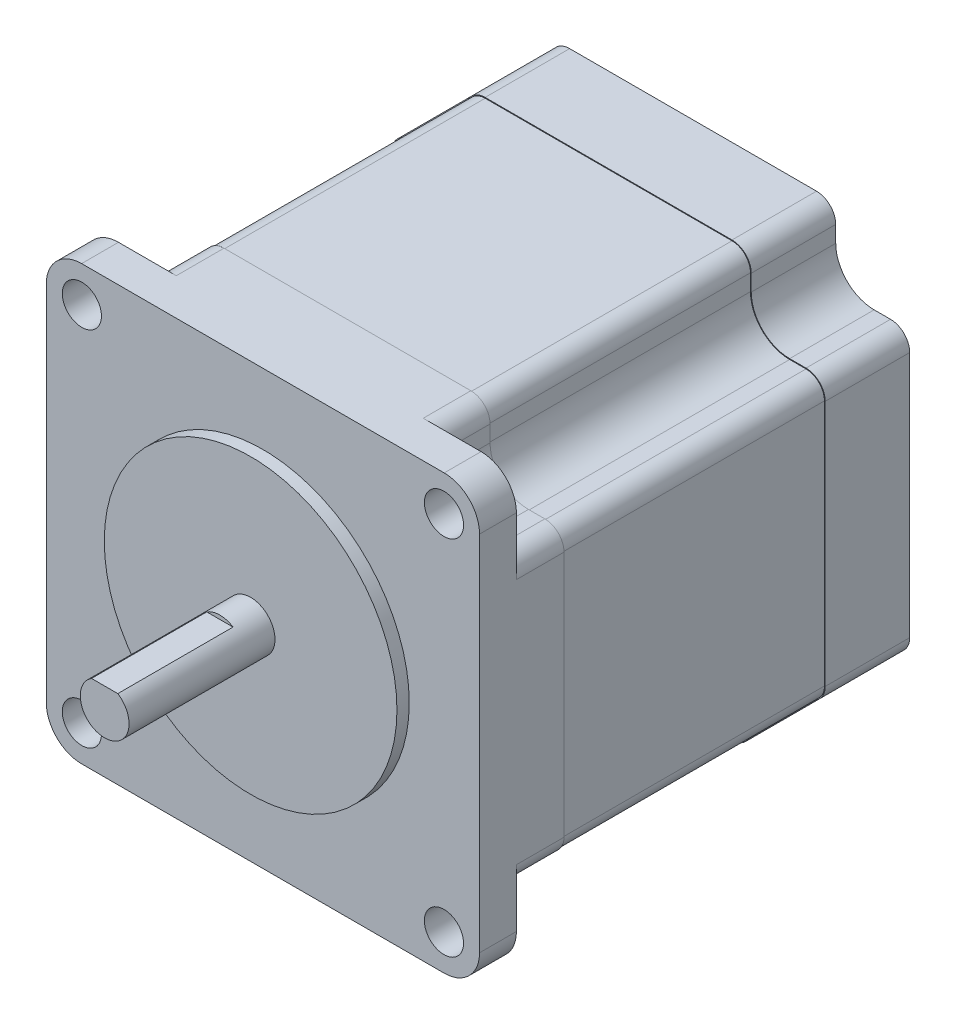
from build123d import *

# Parameters (mm, degrees)
SKETCH1_R           = 3.175
BOSS_EXTRUDE1_DEPTH = 20.6
SKETCH2_R           = 19.05
BOSS_EXTRUDE2_DEPTH = 1.6
BOSS_EXTRUDE3_DEPTH = 4.8
BOSS_EXTRUDE4_DEPTH = 51.2
SKETCH7_W           = 3.420526276
SKETCH7_H           = 1.112659396
CUT_EXTRUDE5_DEPTH  = 15
CUT_EXTRUDE6_REACH  = 58
SKETCH8_R           = 2.55
CUT_EXTRUDE7_DEPTH  = 17


with BuildPart() as part:
    # Sketch1 → Boss-Extrude1 (new body)
    with BuildSketch(Plane.XY):
        Circle(SKETCH1_R)
    extrude(amount=BOSS_EXTRUDE1_DEPTH)

    # Sketch2 → Boss-Extrude2 (add)
    with BuildSketch(Plane(origin=(0, 0, 0), x_dir=(-1, 0, 0), z_dir=(0, 0, -1))):
        Circle(SKETCH2_R)
    extrude(amount=-BOSS_EXTRUDE2_DEPTH)

    # Sketch3 → Boss-Extrude3 (add)
    with BuildSketch(Plane(origin=(0, 0, 0), x_dir=(-1, 0, 0), z_dir=(0, 0, -1))):
        with BuildLine():
            Line((23.6, -28.2), (-23.6, -28.2))
            ThreePointArc((-23.6, -28.2), (-26.852691193, -26.852691193), (-28.2, -23.6))
            Line((-28.2, -23.6), (-28.2, 23.6))
            ThreePointArc((-28.2, 23.6), (-26.852691193, 26.852691193), (-23.6, 28.2))
            Line((-23.6, 28.2), (23.6, 28.2))
            ThreePointArc((23.6, 28.2), (26.852691193, 26.852691193), (28.2, 23.6))
            Line((28.2, 23.6), (28.2, -23.6))
            ThreePointArc((28.2, -23.6), (26.852691193, -26.852691193), (23.6, -28.2))
        make_face()
    extrude(amount=BOSS_EXTRUDE3_DEPTH)

    # Sketch4 → Boss-Extrude4 (add)
    with BuildSketch(Plane(origin=(0, 0, -4.8), x_dir=(-1, 0, 0), z_dir=(0, 0, -1))):
        with BuildLine():
            Line((-18.57, 23.57), (-18.57, 25.7))
            ThreePointArc((-18.57, 25.7), (-17.837766953, 27.467766953), (-16.07, 28.2))
            Line((-16.07, 28.2), (16.07, 28.2))
            ThreePointArc((16.07, 28.2), (17.837766953, 27.467766953), (18.57, 25.7))
            Line((18.57, 25.7), (18.57, 23.57))
            ThreePointArc((18.57, 23.57), (20.034466094, 20.034466094), (23.57, 18.57))
            Line((23.57, 18.57), (25.7, 18.57))
            ThreePointArc((25.7, 18.57), (27.467766953, 17.837766953), (28.2, 16.07))
            Line((28.2, 16.07), (28.2, -16.07))
            ThreePointArc((28.2, -16.07), (27.467766953, -17.837766953), (25.7, -18.57))
            Line((25.7, -18.57), (23.57, -18.57))
            ThreePointArc((23.57, -18.57), (20.034466094, -20.034466094), (18.57, -23.57))
            Line((18.57, -23.57), (18.57, -25.7))
            ThreePointArc((18.57, -25.7), (17.837766953, -27.467766953), (16.07, -28.2))
            Line((16.07, -28.2), (-16.07, -28.2))
            ThreePointArc((-16.07, -28.2), (-17.837766953, -27.467766953), (-18.57, -25.7))
            Line((-18.57, -25.7), (-18.57, -23.57))
            ThreePointArc((-18.57, -23.57), (-20.034466094, -20.034466094), (-23.57, -18.57))
            Line((-23.57, -18.57), (-25.7, -18.57))
            ThreePointArc((-25.7, -18.57), (-27.467766953, -17.837766953), (-28.2, -16.07))
            Line((-28.2, -16.07), (-28.2, 16.07))
            ThreePointArc((-28.2, 16.07), (-27.467766953, 17.837766953), (-25.7, 18.57))
            Line((-25.7, 18.57), (-23.57, 18.57))
            ThreePointArc((-23.57, 18.57), (-20.034466094, 20.034466094), (-18.57, 23.57))
        make_face()
    extrude(amount=BOSS_EXTRUDE4_DEPTH)

    # Sketch7 → Cut-Extrude5 (cut)
    with BuildSketch(Plane.XY.offset(20.6)):
        with Locations((0, 3.231329698)):
            Rectangle(SKETCH7_W, SKETCH7_H)
    extrude(amount=-CUT_EXTRUDE5_DEPTH, mode=Mode.SUBTRACT)

    # Sketch8 → Cut-Extrude6 (cut, up to next)
    with BuildSketch(Plane.XY, mode=Mode.PRIVATE) as cut_extrude6_sk1:
        with Locations((-23.57, 23.57)):
            Circle(SKETCH8_R)
    cut_extrude6_tool1 = extrude(cut_extrude6_sk1.sketch, amount=-CUT_EXTRUDE6_REACH, mode=Mode.PRIVATE) & part.part
    add(cut_extrude6_tool1.solids().sort_by_distance((-23.57, 23.57, 0))[0], mode=Mode.SUBTRACT)
    # Sketch8 → Cut-Extrude6 (cut, up to next)
    with BuildSketch(Plane.XY, mode=Mode.PRIVATE) as cut_extrude6_sk2:
        with Locations((23.57, 23.57)):
            Circle(SKETCH8_R)
    cut_extrude6_tool2 = extrude(cut_extrude6_sk2.sketch, amount=-CUT_EXTRUDE6_REACH, mode=Mode.PRIVATE) & part.part
    add(cut_extrude6_tool2.solids().sort_by_distance((23.57, 23.57, 0))[0], mode=Mode.SUBTRACT)
    # Sketch8 → Cut-Extrude6 (cut, up to next)
    with BuildSketch(Plane.XY, mode=Mode.PRIVATE) as cut_extrude6_sk3:
        with Locations((23.57, -23.57)):
            Circle(SKETCH8_R)
    cut_extrude6_tool3 = extrude(cut_extrude6_sk3.sketch, amount=-CUT_EXTRUDE6_REACH, mode=Mode.PRIVATE) & part.part
    add(cut_extrude6_tool3.solids().sort_by_distance((23.57, -23.57, 0))[0], mode=Mode.SUBTRACT)
    # Sketch8 → Cut-Extrude6 (cut, up to next)
    with BuildSketch(Plane.XY, mode=Mode.PRIVATE) as cut_extrude6_sk4:
        with Locations((-23.57, -23.57)):
            Circle(SKETCH8_R)
    cut_extrude6_tool4 = extrude(cut_extrude6_sk4.sketch, amount=-CUT_EXTRUDE6_REACH, mode=Mode.PRIVATE) & part.part
    add(cut_extrude6_tool4.solids().sort_by_distance((-23.57, -23.57, 0))[0], mode=Mode.SUBTRACT)

    # Sketch9 → Cut-Extrude7 (cut, symmetric)
    with BuildSketch(Plane.XY.offset(-28)):
        with BuildLine():
            Line((18.57, 23.57), (18.57, 25.7))
            ThreePointArc((18.57, 25.7), (17.837766953, 27.467766953), (16.07, 28.2))
            Line((16.07, 28.2), (-16.07, 28.2))
            ThreePointArc((-16.07, 28.2), (-17.837766953, 27.467766953), (-18.57, 25.7))
            Line((-18.57, 25.7), (-18.57, 23.57))
            ThreePointArc((-18.57, 23.57), (-20.034466094, 20.034466094), (-23.57, 18.57))
            Line((-23.57, 18.57), (-25.7, 18.57))
            ThreePointArc((-25.7, 18.57), (-27.467766953, 17.837766953), (-28.2, 16.07))
            Line((-28.2, 16.07), (-28.2, -16.07))
            ThreePointArc((-28.2, -16.07), (-27.467766953, -17.837766953), (-25.7, -18.57))
            Line((-25.7, -18.57), (-23.57, -18.57))
            ThreePointArc((-23.57, -18.57), (-20.034466094, -20.034466094), (-18.57, -23.57))
            Line((-18.57, -23.57), (-18.57, -25.7))
            ThreePointArc((-18.57, -25.7), (-17.837766953, -27.467766953), (-16.07, -28.2))
            Line((-16.07, -28.2), (16.07, -28.2))
            ThreePointArc((16.07, -28.2), (17.837766953, -27.467766953), (18.57, -25.7))
            Line((18.57, -25.7), (18.57, -23.57))
            ThreePointArc((18.57, -23.57), (20.034466094, -20.034466094), (23.57, -18.57))
            Line((23.57, -18.57), (25.7, -18.57))
            ThreePointArc((25.7, -18.57), (27.467766953, -17.837766953), (28.2, -16.07))
            Line((28.2, -16.07), (28.2, 16.07))
            ThreePointArc((28.2, 16.07), (27.467766953, 17.837766953), (25.7, 18.57))
            Line((25.7, 18.57), (23.57, 18.57))
            ThreePointArc((23.57, 18.57), (20.034466094, 20.034466094), (18.57, 23.57))
        make_face()
        with BuildLine():
            Line((18.47, 23.57), (18.47, 25.7))
            ThreePointArc((18.47, 25.7), (17.767056275, 27.397056275), (16.07, 28.1))
            Line((16.07, 28.1), (-16.07, 28.1))
            ThreePointArc((-16.07, 28.1), (-17.767056275, 27.397056275), (-18.47, 25.7))
            Line((-18.47, 25.7), (-18.47, 23.57))
            ThreePointArc((-18.47, 23.57), (-19.963755416, 19.963755416), (-23.57, 18.47))
            Line((-23.57, 18.47), (-25.7, 18.47))
            ThreePointArc((-25.7, 18.47), (-27.397056275, 17.767056275), (-28.1, 16.07))
            Line((-28.1, 16.07), (-28.1, -16.07))
            ThreePointArc((-28.1, -16.07), (-27.397056275, -17.767056275), (-25.7, -18.47))
            Line((-25.7, -18.47), (-23.57, -18.47))
            ThreePointArc((-23.57, -18.47), (-19.963755416, -19.963755416), (-18.47, -23.57))
            Line((-18.47, -23.57), (-18.47, -25.7))
            ThreePointArc((-18.47, -25.7), (-17.767056275, -27.397056275), (-16.07, -28.1))
            Line((-16.07, -28.1), (16.07, -28.1))
            ThreePointArc((16.07, -28.1), (17.767056275, -27.397056275), (18.47, -25.7))
            Line((18.47, -25.7), (18.47, -23.57))
            ThreePointArc((18.47, -23.57), (19.963755416, -19.963755416), (23.57, -18.47))
            Line((23.57, -18.47), (25.7, -18.47))
            ThreePointArc((25.7, -18.47), (27.397056275, -17.767056275), (28.1, -16.07))
            Line((28.1, -16.07), (28.1, 16.07))
            ThreePointArc((28.1, 16.07), (27.397056275, 17.767056275), (25.7, 18.47))
            Line((25.7, 18.47), (23.57, 18.47))
            ThreePointArc((23.57, 18.47), (19.963755416, 19.963755416), (18.47, 23.57))
        make_face(mode=Mode.SUBTRACT)
    extrude(amount=CUT_EXTRUDE7_DEPTH, both=True, mode=Mode.SUBTRACT)


solid = part.part
